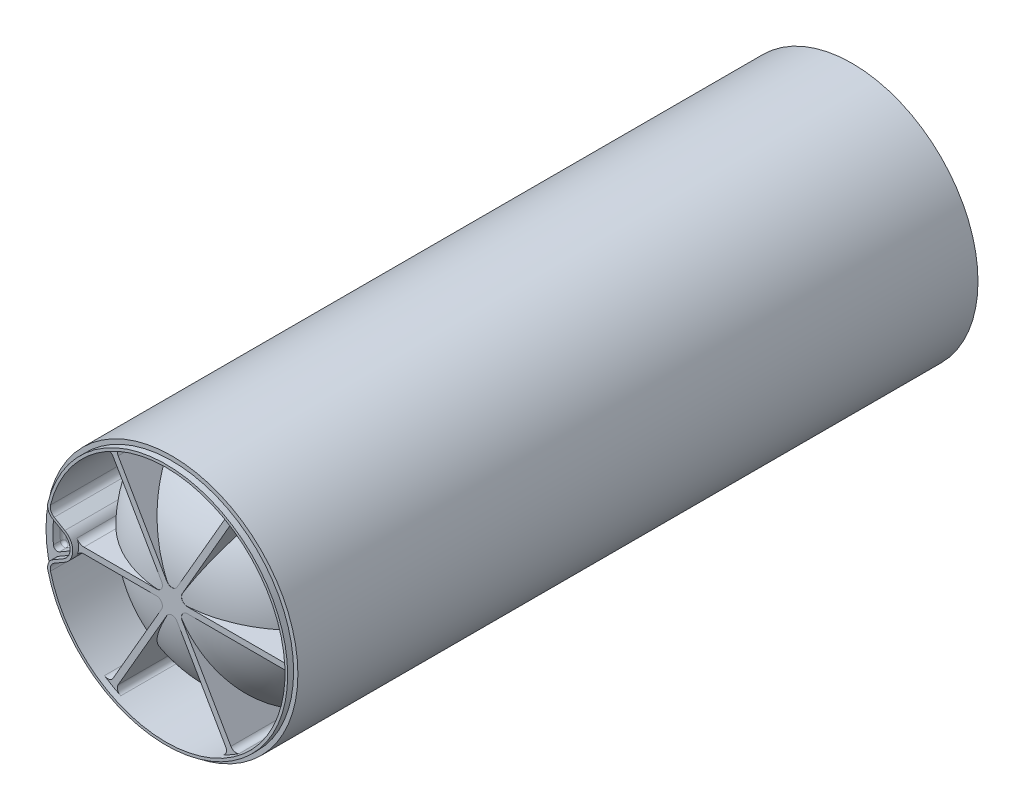
from build123d import *

# Parameters (mm, degrees)
SKETCH1_R           = 63.5
BOSS_EXTRUDE1_DEPTH = 342.9
FILLET1_R           = 60
SHELL1_T            = -1.5875
BOSS_EXTRUDE6_REACH = 377.671
SKETCH8_R           = 63.5
CUT_EXTRUDE1_DEPTH  = 5
SKETCH12_R          = 2
CUT_EXTRUDE2_DEPTH  = 30
SKETCH13_R          = 4
CUT_EXTRUDE3_DEPTH  = 327.56
BOSS_EXTRUDE7_DEPTH = 1.5
FILLET2_R           = 1.5
MOVE_FACE1_BY       = 1.5


with BuildPart() as part:
    # Sketch1 → Boss-Extrude1 (new body)
    with BuildSketch(Plane.XY):
        with Locations((-76.2, 0)):
            Circle(SKETCH1_R)
    extrude(amount=BOSS_EXTRUDE1_DEPTH)

    # Fillet1
    fillet1_edges = [part.edges().sort_by_distance(p)[0] for p in [
        (-139.7, 0, 342.9),
    ]]
    fillet(fillet1_edges, radius=FILLET1_R)

    # Shell1
    shell1_openings = [part.faces().sort_by_distance(p)[0] for p in [
        (-76.2, 0, 0),
    ]]
    offset(amount=SHELL1_T, openings=shell1_openings, kind=Kind.INTERSECTION)

    # Sketch8 → Boss-Extrude6 (add, up to next)
    with BuildSketch(Plane.XY.offset(342.9), mode=Mode.PRIVATE) as boss_extrude6_sk1:
        with Locations((-76.2, 0)):
            Circle(SKETCH8_R)
        with BuildLine():
            Line((-120.534635496, -1.5), (-83.994228634, -1.5))
            ThreePointArc((-83.994228634, -1.5), (-81.396152423, -3), (-81.396152423, -6))
            Line((-81.396152423, -6), (-105.910083493, -48.459374107))
            ThreePointArc((-105.910083493, -48.459374107), (-107.846783991, -49.885563125), (-110.208589162, -49.430920113))
            ThreePointArc((-110.208589162, -49.430920113), (-125.527605856, -34.158268407), (-134.435045516, -14.445742407))
            ThreePointArc((-134.435045516, -14.445742407), (-134.233794182, -11.917568963), (-132.552709149, -10.018591298))
            Line((-132.552709149, -10.018591298), (-127.2, -6.92820323))
            ThreePointArc((-127.2, -6.92820323), (-125.410459424, -5.520979978), (-124.089756997, -3.666666667))
            ThreePointArc((-124.089756997, -3.666666667), (-122.616301496, -2.084349745), (-120.534635496, -1.5))
        make_face(mode=Mode.SUBTRACT)
        with BuildLine():
            Line((-105.910083493, 48.459374107), (-81.396152423, 6))
            ThreePointArc((-81.396152423, 6), (-81.396152423, 3), (-83.994228634, 1.5))
            Line((-83.994228634, 1.5), (-120.534635496, 1.5))
            ThreePointArc((-120.534635496, 1.5), (-122.616301496, 2.084349745), (-124.089756997, 3.666666667))
            ThreePointArc((-124.089756997, 3.666666667), (-125.410459424, 5.520979978), (-127.2, 6.92820323))
            Line((-127.2, 6.92820323), (-132.552709149, 10.018591298))
            ThreePointArc((-132.552709149, 10.018591298), (-134.233794182, 11.917568963), (-134.435045516, 14.445742407))
            ThreePointArc((-134.435045516, 14.445742407), (-125.527605856, 34.158268407), (-110.208589162, 49.430920113))
            ThreePointArc((-110.208589162, 49.430920113), (-107.846783991, 49.885563125), (-105.910083493, 48.459374107))
        make_face(mode=Mode.SUBTRACT)
        with BuildLine():
            Line((-103.312007282, -49.959374107), (-78.798076211, -7.5))
            ThreePointArc((-78.798076211, -7.5), (-76.2, -6), (-73.601923789, -7.5))
            Line((-73.601923789, -7.5), (-49.087992718, -49.959374107))
            ThreePointArc((-49.087992718, -49.959374107), (-48.821227048, -52.349700447), (-50.395862031, -54.167762218))
            ThreePointArc((-50.395862031, -54.167762218), (-76.2, -60), (-102.004137969, -54.167762218))
            ThreePointArc((-102.004137969, -54.167762218), (-103.578772952, -52.349700447), (-103.312007282, -49.959374107))
        make_face(mode=Mode.SUBTRACT)
        with BuildLine():
            Line((-103.312007282, 49.959374107), (-78.798076211, 7.5))
            ThreePointArc((-78.798076211, 7.5), (-76.2, 6), (-73.601923789, 7.5))
            Line((-73.601923789, 7.5), (-49.087992718, 49.959374107))
            ThreePointArc((-49.087992718, 49.959374107), (-48.821227048, 52.349700447), (-50.395862031, 54.167762218))
            ThreePointArc((-50.395862031, 54.167762218), (-76.2, 60), (-102.004137969, 54.167762218))
            ThreePointArc((-102.004137969, 54.167762218), (-103.578772952, 52.349700447), (-103.312007282, 49.959374107))
        make_face(mode=Mode.SUBTRACT)
        with BuildLine():
            Line((-68.405771366, 1.5), (-19.377909225, 1.5))
            ThreePointArc((-19.377909225, 1.5), (-17.174443056, 2.464137322), (-16.387272869, 4.736842105))
            ThreePointArc((-16.387272869, 4.736842105), (-24.238475773, 30), (-42.191410838, 49.430920113))
            ThreePointArc((-42.191410838, 49.430920113), (-44.553216009, 49.885563125), (-46.489916507, 48.459374107))
            Line((-46.489916507, 48.459374107), (-71.003847577, 6))
            ThreePointArc((-71.003847577, 6), (-71.003847577, 3), (-68.405771366, 1.5))
        make_face(mode=Mode.SUBTRACT)
        with BuildLine():
            Line((-71.003847577, -6), (-46.489916507, -48.459374107))
            ThreePointArc((-46.489916507, -48.459374107), (-44.553216009, -49.885563125), (-42.191410838, -49.430920113))
            ThreePointArc((-42.191410838, -49.430920113), (-24.238475773, -30), (-16.387272869, -4.736842105))
            ThreePointArc((-16.387272869, -4.736842105), (-17.174443056, -2.464137322), (-19.377909225, -1.5))
            Line((-19.377909225, -1.5), (-68.405771366, -1.5))
            ThreePointArc((-68.405771366, -1.5), (-71.003847577, -3), (-71.003847577, -6))
        make_face(mode=Mode.SUBTRACT)
    boss_extrude6_tool1 = extrude(boss_extrude6_sk1.sketch, amount=-BOSS_EXTRUDE6_REACH, mode=Mode.PRIVATE) - part.part
    add(boss_extrude6_tool1.solids().sort_by_distance((-79.586292, 0, 342.9))[0])

    # Sketch11 → Cut-Extrude1 (cut)
    with BuildSketch(Plane.XY.offset(342.9)):
        with BuildLine():
            Line((-132.978150632, 6.800118438), (-128.7, 4.330127019))
            ThreePointArc((-128.7, 4.330127019), (-126.2, 0), (-128.7, -4.330127019))
            Line((-128.7, -4.330127019), (-132.978150632, -6.800118438))
            ThreePointArc((-132.978150632, -6.800118438), (-134.901447748, -6.842193454), (-135.970500654, -5.242828583))
            ThreePointArc((-135.970500654, -5.242828583), (-136.2, 0), (-135.970500654, 5.242828583))
            ThreePointArc((-135.970500654, 5.242828583), (-134.901447748, 6.842193453), (-132.978150632, 6.800118438))
        make_face()
    extrude(amount=-CUT_EXTRUDE1_DEPTH, mode=Mode.SUBTRACT)

    # Sketch12 → Cut-Extrude2 (cut)
    with BuildSketch(Plane.XY.offset(337.9)):
        with Locations((-131.2, 0)):
            Circle(SKETCH12_R)
    extrude(amount=-CUT_EXTRUDE2_DEPTH, mode=Mode.SUBTRACT)

    # Sketch13 → Cut-Extrude3 (cut)
    with BuildSketch(Plane(origin=(0, 0, 0), x_dir=(-1, 0, 0), z_dir=(0, 0, -1))):
        with Locations((131.2, 0)):
            Circle(SKETCH13_R)
    extrude(amount=-CUT_EXTRUDE3_DEPTH, mode=Mode.SUBTRACT)

    # Sketch9 → Boss-Extrude7 (add)
    with BuildSketch(Plane.XY.offset(342.9)):
        with BuildLine():
            Line((-133.227709149, 8.849457003), (-127.875, 5.759068935))
            ThreePointArc((-127.875, 5.759068935), (-124.55, 0), (-127.875, -5.759068935))
            Line((-127.875, -5.759068935), (-133.227709149, -8.849457003))
            ThreePointArc((-133.227709149, -8.849457003), (-135.476160381, -11.38933963), (-135.745334041, -14.770771611))
            ThreePointArc((-135.745334041, -14.770771611), (-14.85, 0), (-135.745334041, 14.770771611))
            ThreePointArc((-135.745334041, 14.770771611), (-135.476160381, 11.38933963), (-133.227709149, 8.849457003))
        make_face()
        with BuildLine():
            Line((-132.552709149, 10.018591298), (-127.2, 6.92820323))
            ThreePointArc((-127.2, 6.92820323), (-123.2, 0), (-127.2, -6.92820323))
            Line((-127.2, -6.92820323), (-132.552709149, -10.018591298))
            ThreePointArc((-132.552709149, -10.018591298), (-134.233794182, -11.917568963), (-134.435045516, -14.445742407))
            ThreePointArc((-134.435045516, -14.445742407), (-16.2, 0), (-134.435045516, 14.445742407))
            ThreePointArc((-134.435045516, 14.445742407), (-134.233794182, 11.917568963), (-132.552709149, 10.018591298))
        make_face(mode=Mode.SUBTRACT)
    extrude(amount=BOSS_EXTRUDE7_DEPTH)

    # Fillet2
    fillet2_edges = [part.edges().sort_by_distance(p)[0] for p in [
        (-134.901447748, -6.842193454, 337.9),
        (-136.2, 0, 337.9),
        (-134.901447748, 6.842193453, 337.9),
        (-126.2, 0, 337.9),
        (-130.839075316, -5.565122729, 337.9),
        (-130.839075316, 5.565122729, 337.9),
        (-127.2, 0, 327.56),
    ]]
    fillet(fillet2_edges, radius=FILLET2_R)

    # Move Face1: a face moved outward by 1.5
    extrude(part.faces().sort_by_distance((-123.797438234, 0, 344.4))[0], amount=MOVE_FACE1_BY, dir=(0, 0, 1))


solid = part.part
